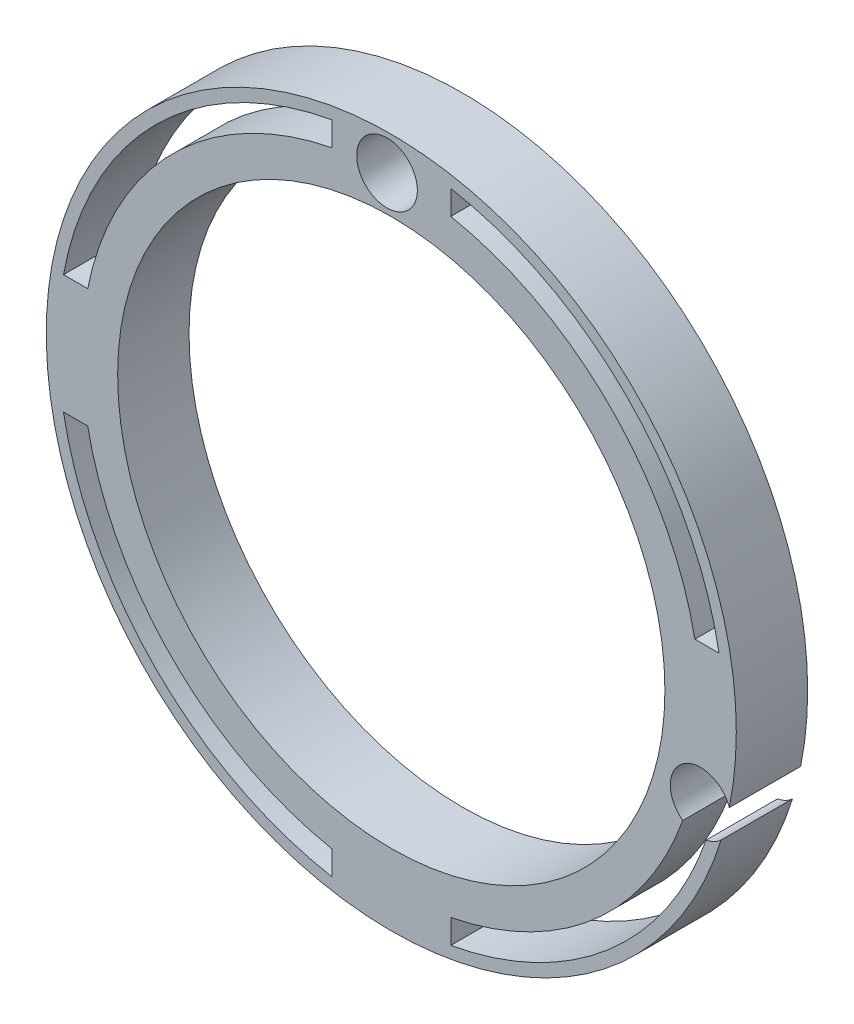
from build123d import *

# Parameters (mm, degrees)
CUT_EXTRUDE1_DEPTH = 7
SKETCH4_R          = 2.55
CUT_EXTRUDE2_DEPTH = 7


with BuildPart() as part:
    # Sketch2 → Revolve1 (revolve)
    with BuildSketch(Plane.ZY.offset(-259.301545348)):
        Polygon((0, -124.073704322), (0, -125.573704322), (6, -125.573704322), (6, -119.573704322), (0, -119.573704322), (0, -121.073704322), (2, -121.073704322), (2, -124.073704322), align=None)
    revolve(axis=Axis((259.301545348, -148.573704322, 22.865), (0, 0, 1)))

    # Sketch3 → Cut-Extrude1 (cut, through all)
    with BuildSketch(Plane.XY.offset(6)):
        with BuildLine():
            Line((254.301545348, -174.088405967), (254.301545348, -176.12365895))
            ThreePointArc((254.301545348, -176.12365895), (239.502555475, -168.372694195), (231.75159072, -153.573704322))
            Line((231.75159072, -153.573704322), (233.786843704, -153.573704322))
            ThreePointArc((233.786843704, -153.573704322), (240.916769037, -166.958480633), (254.301545348, -174.088405967))
        make_face()
        with BuildLine():
            Line((264.301545348, -174.088405967), (264.301545348, -176.12365895))
            ThreePointArc((264.301545348, -176.12365895), (279.100535221, -168.372694195), (286.851499976, -153.573704322))
            Line((286.851499976, -153.573704322), (284.816246992, -153.573704322))
            ThreePointArc((284.816246992, -153.573704322), (277.686321659, -166.958480633), (264.301545348, -174.088405967))
        make_face()
        with BuildLine():
            Line((286.851499976, -143.573704322), (284.816246992, -143.573704322))
            ThreePointArc((284.816246992, -143.573704322), (277.686321659, -130.188928011), (264.301545348, -123.059002678))
            Line((264.301545348, -123.059002678), (264.301545348, -121.023749694))
            ThreePointArc((264.301545348, -121.023749694), (279.100535221, -128.774714449), (286.851499976, -143.573704322))
        make_face()
        with BuildLine():
            Line((254.301545348, -121.023749694), (254.301545348, -123.059002678))
            ThreePointArc((254.301545348, -123.059002678), (240.916769037, -130.188928011), (233.786843704, -143.573704322))
            Line((233.786843704, -143.573704322), (231.75159072, -143.573704322))
            ThreePointArc((231.75159072, -143.573704322), (239.502555475, -128.774714449), (254.301545348, -121.023749694))
        make_face()
    extrude(amount=-CUT_EXTRUDE1_DEPTH, mode=Mode.SUBTRACT)

    # Sketch4 → Cut-Extrude2 (cut, through all)
    with BuildSketch(Plane.XY.offset(6)):
        with Locations((258.944661735, -122.573704322)):
            Circle(SKETCH4_R)
        with Locations((285.301545348, -155.216820709)):
            Circle(SKETCH4_R)
        with Locations((252.658428961, -181.573704322)):
            Circle(SKETCH4_R)
        with Locations((226.301545348, -148.930587935)):
            Circle(SKETCH4_R)
    extrude(amount=-CUT_EXTRUDE2_DEPTH, mode=Mode.SUBTRACT)


solid = part.part
